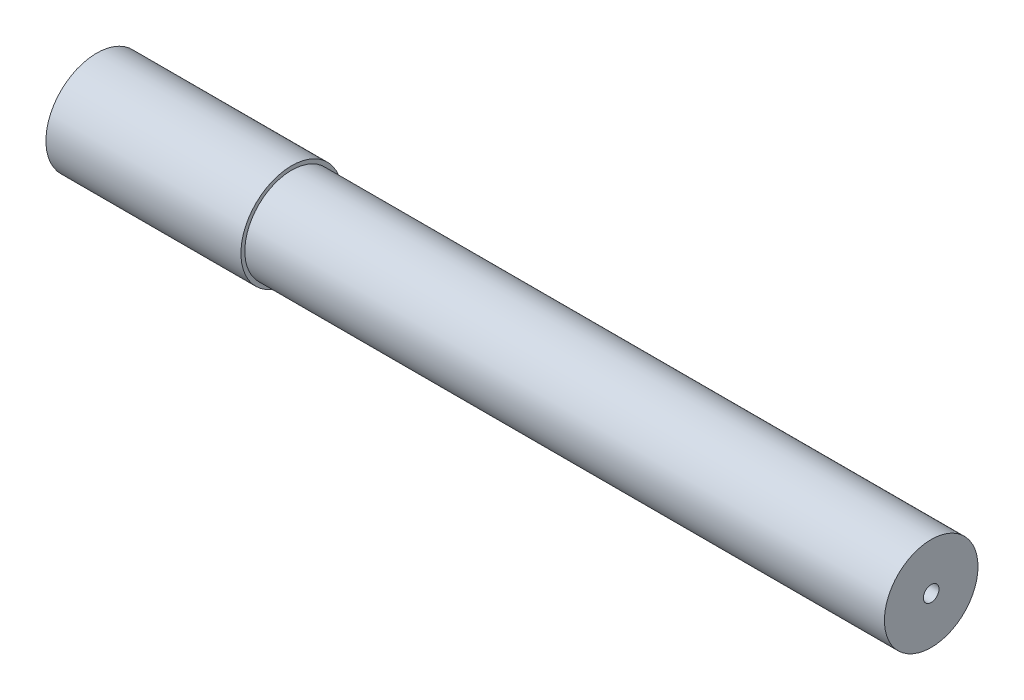
from build123d import *


with BuildPart() as part:
    # Sketch1 → Revolve1 (revolve)
    with BuildSketch(Plane.XY):
        Polygon((10, 0.5), (11, 0.5), (11, 3), (-30, 3), (-30, 3.25), (-42.5, 3.25), (-42.5, 2.25), (10, 2.25), align=None)
    revolve(axis=Axis((13.5, 0, 0), (-1, 0, 0)))


solid = part.part
